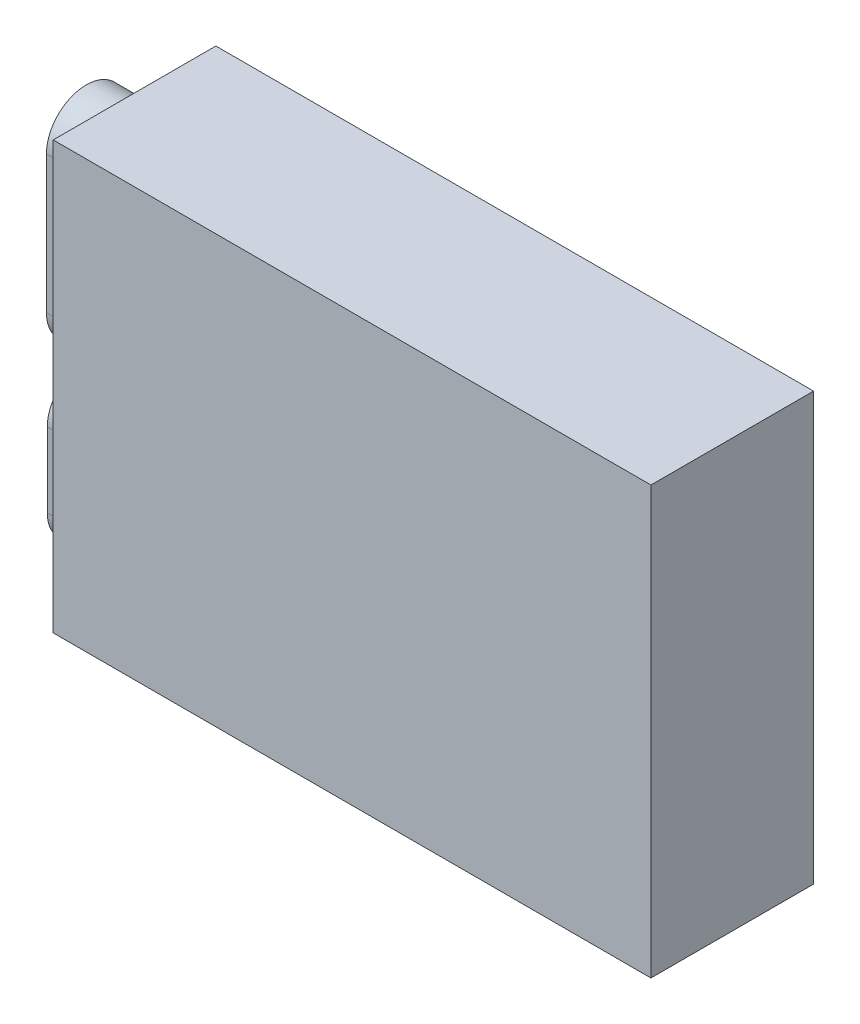
from build123d import *

# Parameters (mm, degrees)
SKETCH1_W           = 147
SKETCH1_H           = 105
BOSS_EXTRUDE4_DEPTH = 40
BOSS_EXTRUDE5_DEPTH = 12.7
CUT_EXTRUDE3_DEPTH  = 10.16
BOSS_EXTRUDE6_DEPTH = 12.7
CUT_EXTRUDE4_DEPTH  = 10.16


with BuildPart() as part:
    # Sketch1 → Boss-Extrude4 (new body)
    with BuildSketch(Plane.XY):
        Rectangle(SKETCH1_W, SKETCH1_H)
    extrude(amount=BOSS_EXTRUDE4_DEPTH)

    # Sketch6 → Boss-Extrude5 (add)
    with BuildSketch(Plane.ZY.offset(73.5)):
        with BuildLine():
            Line((9.360303109, 3.859497892), (9.360303109, 37.656182133))
            ThreePointArc((9.360303109, 37.656182133), (19.165513969, 47.461392993), (28.970724829, 37.656182133))
            Line((28.970724829, 37.656182133), (28.970724829, 3.859497892))
            ThreePointArc((28.970724829, 3.859497892), (19.165513969, -5.945712968), (9.360303109, 3.859497892))
        make_face()
    extrude(amount=BOSS_EXTRUDE5_DEPTH)

    # Sketch7 → Cut-Extrude3 (cut)
    with BuildSketch(Plane.ZY.offset(86.2)):
        with BuildLine():
            Line((12.154400228, 3.770764543), (11.749992656, 37.567448784))
            ThreePointArc((11.749992656, 37.567448784), (19.076780621, 45.071703446), (26.581035283, 37.744915482))
            Line((26.581035283, 37.744915482), (26.985442854, 3.94823124))
            ThreePointArc((26.985442854, 3.94823124), (19.65865489, -3.556023421), (12.154400228, 3.770764543))
        make_face()
    extrude(amount=-CUT_EXTRUDE3_DEPTH, mode=Mode.SUBTRACT)

    # Sketch8 → Boss-Extrude6 (add)
    with BuildSketch(Plane.ZY.offset(73.5)):
        with BuildLine():
            Line((10.403410648, -38.907911179), (10.403410648, -20.549218505))
            ThreePointArc((10.403410648, -20.549218505), (19.582756985, -11.369872168), (28.762103322, -20.549218505))
            Line((28.762103322, -20.549218505), (28.762103322, -38.907911179))
            ThreePointArc((28.762103322, -38.907911179), (19.582756985, -48.087257516), (10.403410648, -38.907911179))
        make_face()
    extrude(amount=BOSS_EXTRUDE6_DEPTH)

    # Sketch9 → Cut-Extrude4 (cut)
    with BuildSketch(Plane.ZY.offset(86.2)):
        with BuildLine():
            Line((12.388273633, -38.928322069), (12.336561358, -20.569629395))
            ThreePointArc((12.336561358, -20.569629395), (19.562346094, -13.303022878), (26.828952612, -20.528807614))
            Line((26.828952612, -20.528807614), (26.880664887, -38.887500288))
            ThreePointArc((26.880664887, -38.887500288), (19.654880151, -46.154106806), (12.388273633, -38.928322069))
        make_face()
    extrude(amount=-CUT_EXTRUDE4_DEPTH, mode=Mode.SUBTRACT)


solid = part.part
